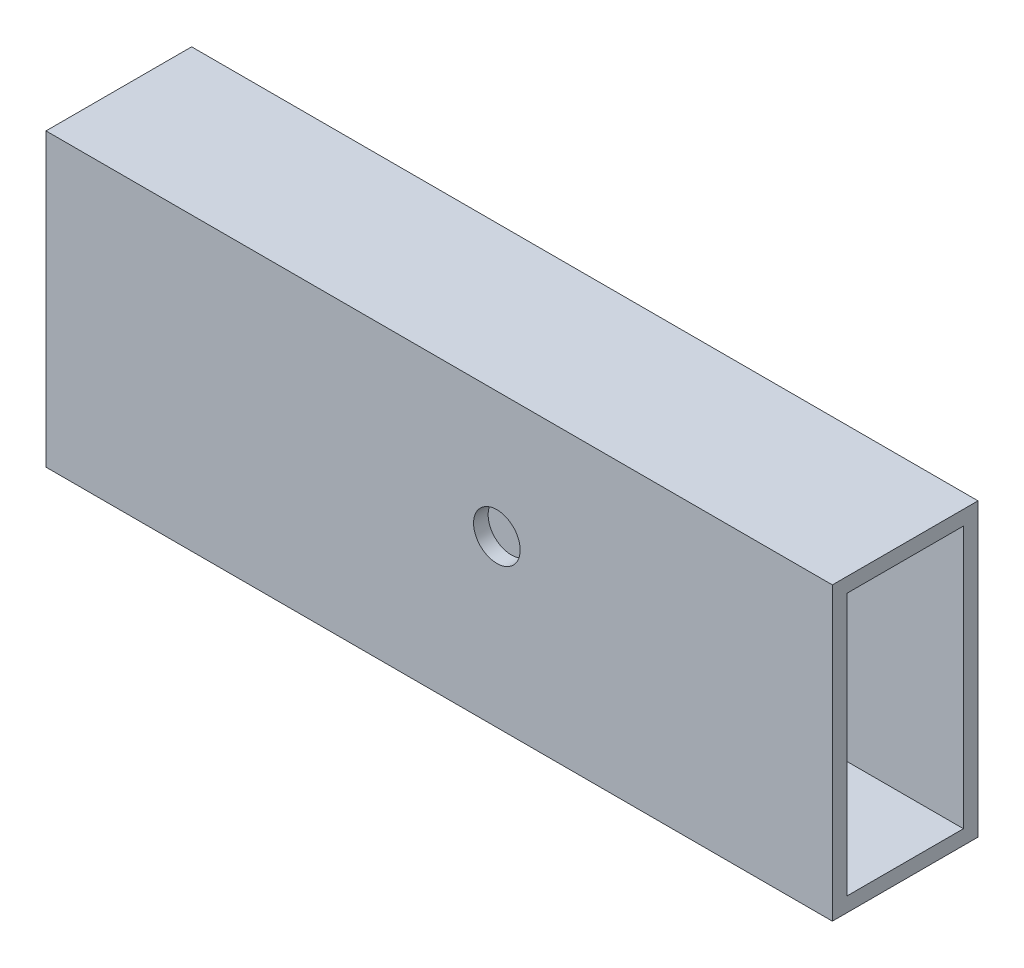
from build123d import *

# Parameters (mm, degrees)
SKETCH5_W           = 25
SKETCH5_H           = 50
BOSS_EXTRUDE2_DEPTH = 135
SKETCH6_W           = 20
SKETCH6_H           = 45
CUT_EXTRUDE1_DEPTH  = 135
SKETCH7_R           = 4
CUT_EXTRUDE4_DEPTH  = 13.5


with BuildPart() as part:
    # Sketch5 → Boss-Extrude2 (new body)
    with BuildSketch(Plane(origin=(0, 0, 0), x_dir=(0, 0, -1), z_dir=(1, 0, 0))):
        Rectangle(SKETCH5_W, SKETCH5_H)
    extrude(amount=-BOSS_EXTRUDE2_DEPTH)

    # Sketch6 → Cut-Extrude1 (cut)
    with BuildSketch(Plane(origin=(0, 0, 0), x_dir=(0, 0, -1), z_dir=(1, 0, 0))):
        Rectangle(SKETCH6_W, SKETCH6_H)
    extrude(amount=-CUT_EXTRUDE1_DEPTH, mode=Mode.SUBTRACT)

    # Sketch7 → Cut-Extrude4 (cut, through all)
    with BuildSketch(Plane.XY):
        with Locations((-57.600290454, 3.389089755)):
            Circle(SKETCH7_R)
    extrude(amount=CUT_EXTRUDE4_DEPTH, mode=Mode.SUBTRACT)


solid = part.part
